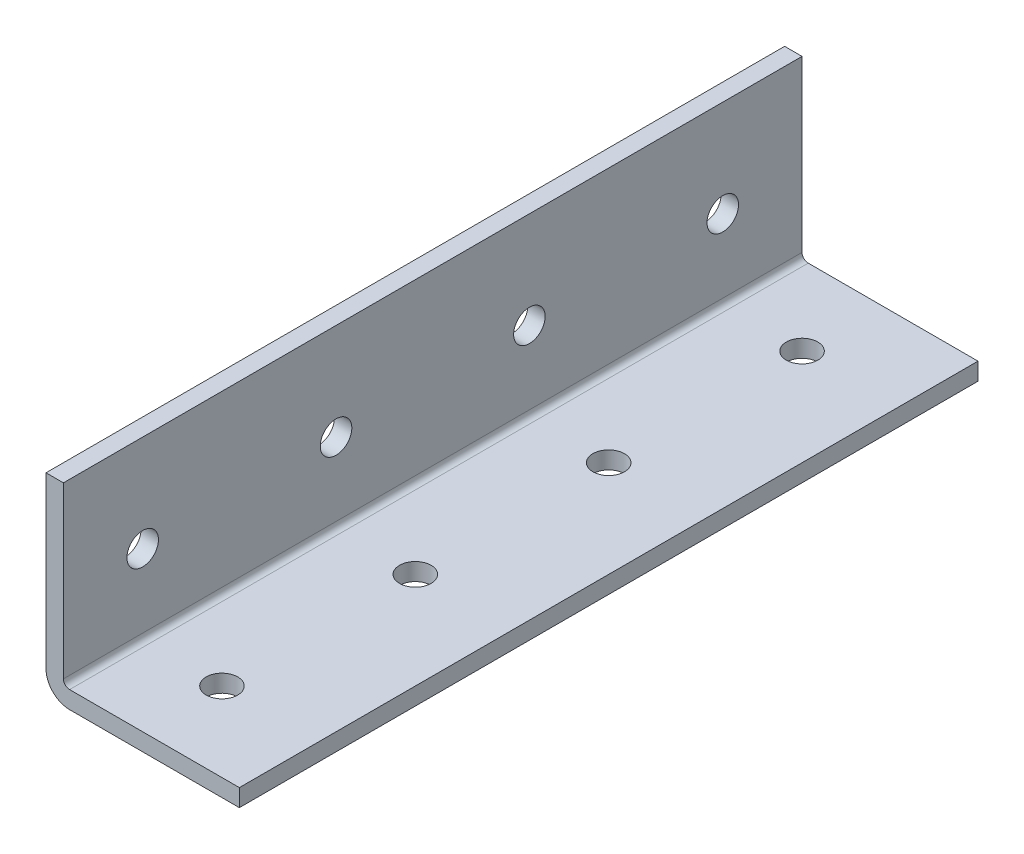
from build123d import *

# Parameters (mm, degrees)
SKETCH1_W                  = 25.4
SKETCH1_H                  = 1498.6
BOSS_EXTRUDE1_DEPTH        = 25.4
SKETCH2_W                  = 23.114
SKETCH2_H                  = 23.114
CUT_EXTRUDE1_DEPTH         = 1499.6
M3_5_CLEARANCE_HOLE1_D     = 4.1402
M3_5_CLEARANCE_HOLE1_DEPTH = 25.4
M3_5_CLEARANCE_HOLE2_D     = 4.1402
M3_5_CLEARANCE_HOLE2_DEPTH = 25.4
CHAMFER1_SIZE              = 2.159
FILLET1_R                  = 0.8128
FILLET2_R                  = 3.0988
SKETCH8_W                  = 95.882963774
SKETCH8_H                  = 79.338329604
CUT_EXTRUDE3_DEPTH         = 1397
SKETCH9_W                  = 55.647897921
SKETCH9_H                  = 59.659370493
CUT_EXTRUDE4_DEPTH         = 2.286
SKETCH10_W                 = 60.180202688
SKETCH10_H                 = 53.53268885
CUT_EXTRUDE5_DEPTH         = 2.286


with BuildPart() as part:
    # Sketch1 → Boss-Extrude1 (new body)
    with BuildSketch(Plane(origin=(0, 0, 0), x_dir=(0, -1, 0), z_dir=(-1, 0, 0))):
        with Locations((-12.7, 0)):
            Rectangle(SKETCH1_W, SKETCH1_H)
    extrude(amount=-BOSS_EXTRUDE1_DEPTH)

    # Sketch2 → Cut-Extrude1 (cut, through all)
    with BuildSketch(Plane(origin=(0, 0, -749.3), x_dir=(-1, 0, 0), z_dir=(0, 0, -1))):
        with Locations((-13.843, 13.843)):
            Rectangle(SKETCH2_W, SKETCH2_H)
    extrude(amount=-CUT_EXTRUDE1_DEPTH, mode=Mode.SUBTRACT)

    # M3.5 Clearance Hole1
    with Locations(Plane(origin=(0, 0, 0), x_dir=(-1, 0, 0), z_dir=(0, -1, 0))):
        with Locations((-12.7, 736.6), (-12.7, 711.2), (-12.7, 685.8), (-12.7, 660.4), (-12.7, 635), (-12.7, 609.6), (-12.7, 584.2), (-12.7, 558.8), (-12.7, 533.4), (-12.7, 508), (-12.7, 482.6), (-12.7, 457.2), (-12.7, 431.8), (-12.7, 406.4), (-12.7, 381), (-12.7, 355.6), (-12.7, 330.2), (-12.7, 304.8), (-12.7, 279.4), (-12.7, 254), (-12.7, 228.6), (-12.7, 203.2), (-12.7, 177.8), (-12.7, 152.4), (-12.7, 127), (-12.7, 101.6), (-12.7, 76.2), (-12.7, 50.8), (-12.7, 25.4), (-12.7, 0), (-12.7, -25.4), (-12.7, -50.8), (-12.7, -76.2), (-12.7, -101.6), (-12.7, -127), (-12.7, -152.4), (-12.7, -177.8), (-12.7, -203.2), (-12.7, -228.6), (-12.7, -254), (-12.7, -279.4), (-12.7, -304.8), (-12.7, -330.2), (-12.7, -355.6), (-12.7, -381), (-12.7, -406.4), (-12.7, -431.8), (-12.7, -457.2), (-12.7, -482.6), (-12.7, -508), (-12.7, -533.4), (-12.7, -558.8), (-12.7, -584.2), (-12.7, -609.6), (-12.7, -635), (-12.7, -660.4), (-12.7, -685.8), (-12.7, -711.2), (-12.7, -736.6)):
            Hole(M3_5_CLEARANCE_HOLE1_D / 2, depth=M3_5_CLEARANCE_HOLE1_DEPTH)

    # M3.5 Clearance Hole2
    with Locations(Plane.ZY):
        with Locations((711.2, 12.7), (736.6, 12.7), (685.8, 12.7), (660.4, 12.7), (635, 12.7), (609.6, 12.7), (584.2, 12.7), (558.8, 12.7), (533.4, 12.7), (508, 12.7), (482.6, 12.7), (457.2, 12.7), (431.8, 12.7), (406.4, 12.7), (381, 12.7), (355.6, 12.7), (330.2, 12.7), (304.8, 12.7), (279.4, 12.7), (254, 12.7), (228.6, 12.7), (203.2, 12.7), (177.8, 12.7), (152.4, 12.7), (127, 12.7), (101.6, 12.7), (76.2, 12.7), (50.8, 12.7), (25.4, 12.7), (0, 12.7), (-25.4, 12.7), (-50.8, 12.7), (-76.2, 12.7), (-101.6, 12.7), (-127, 12.7), (-152.4, 12.7), (-177.8, 12.7), (-203.2, 12.7), (-228.6, 12.7), (-254, 12.7), (-279.4, 12.7), (-304.8, 12.7), (-330.2, 12.7), (-355.6, 12.7), (-381, 12.7), (-406.4, 12.7), (-431.8, 12.7), (-457.2, 12.7), (-482.6, 12.7), (-508, 12.7), (-533.4, 12.7), (-558.8, 12.7), (-584.2, 12.7), (-609.6, 12.7), (-635, 12.7), (-660.4, 12.7), (-685.8, 12.7), (-711.2, 12.7), (-736.6, 12.7)):
            Hole(M3_5_CLEARANCE_HOLE2_D / 2, depth=M3_5_CLEARANCE_HOLE2_DEPTH)

    # Chamfer1
    chamfer1_edges = [part.edges().sort_by_distance(p)[0] for p in [
        (25.4, 1.143, -749.3),
        (1.143, 25.4, 749.3),
        (1.143, 25.4, -749.3),
        (25.4, 1.143, 749.3),
    ]]
    chamfer(chamfer1_edges, length=CHAMFER1_SIZE)

    # Fillet1
    fillet1_edges = [part.edges().sort_by_distance(p)[0] for p in [
        (2.286, 2.286, 0),
    ]]
    fillet(fillet1_edges, radius=FILLET1_R)

    # Fillet2
    fillet2_edges = [part.edges().sort_by_distance(p)[0] for p in [
        (0, 0, 0),
    ]]
    fillet(fillet2_edges, radius=FILLET2_R)

    # Sketch8 → Cut-Extrude3 (cut)
    with BuildSketch(Plane.XY.offset(749.3)):
        with Locations((2.286, 3.0988)):
            Rectangle(SKETCH8_W, SKETCH8_H)
    extrude(amount=-CUT_EXTRUDE3_DEPTH, mode=Mode.SUBTRACT)

    # Sketch9 → Cut-Extrude4 (cut)
    with BuildSketch(Plane.XY.offset(-647.7)):
        with Locations((1.567971806, 1.525578147)):
            Rectangle(SKETCH9_W, SKETCH9_H)
    extrude(amount=-CUT_EXTRUDE4_DEPTH, mode=Mode.SUBTRACT)

    # Sketch10 → Cut-Extrude5 (cut)
    with BuildSketch(Plane(origin=(0, 0, -749.3), x_dir=(-1, 0, 0), z_dir=(0, 0, -1))):
        with Locations((-0.996649486, 3.303060092)):
            Rectangle(SKETCH10_W, SKETCH10_H)
    extrude(amount=-CUT_EXTRUDE5_DEPTH, mode=Mode.SUBTRACT)


solid = part.part
